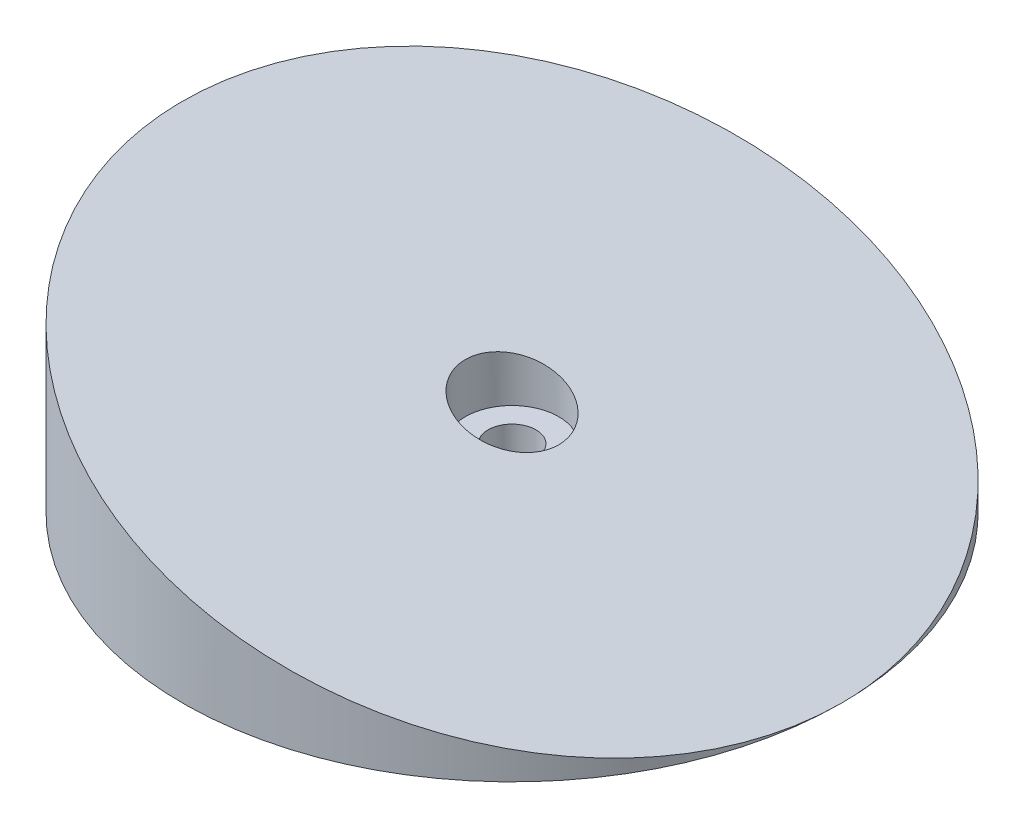
from build123d import *

# Parameters (mm, degrees)
SKETCH1_R               = 55
SKETCH1_R_2             = 4
BOSS_EXTRUDE1_DEPTH     = 32
CUT_EXTRUDE1_DEPTH      = 56
CUT_EXTRUDE1_DEPTH_BACK = 56
SKETCH4_R               = 7.796617101
CUT_EXTRUDE2_DEPTH      = 23


with BuildPart() as part:
    # Sketch1 → Boss-Extrude1 (new body)
    with BuildSketch(Plane(origin=(0, 0, 0), x_dir=(1, 0, 0), z_dir=(0, 1, 0))):
        Circle(SKETCH1_R)
        Circle(SKETCH1_R_2, mode=Mode.SUBTRACT)
    extrude(amount=BOSS_EXTRUDE1_DEPTH)

    # Sketch3 → Cut-Extrude1 (cut, two sides)
    with BuildSketch(Plane.XY) as cut_extrude1_sk:
        Polygon((55, 0), (55, 32), (-55, 32), align=None)
    extrude(amount=CUT_EXTRUDE1_DEPTH, mode=Mode.SUBTRACT)
    extrude(cut_extrude1_sk.sketch, amount=-CUT_EXTRUDE1_DEPTH_BACK, mode=Mode.SUBTRACT)

    # Sketch4 → Cut-Extrude2 (cut, through all)
    with BuildSketch(Plane(origin=(0, 10, 0), x_dir=(1, 0, 0), z_dir=(0, 1, 0))):
        Circle(SKETCH4_R)
    extrude(amount=CUT_EXTRUDE2_DEPTH, mode=Mode.SUBTRACT)


solid = part.part
